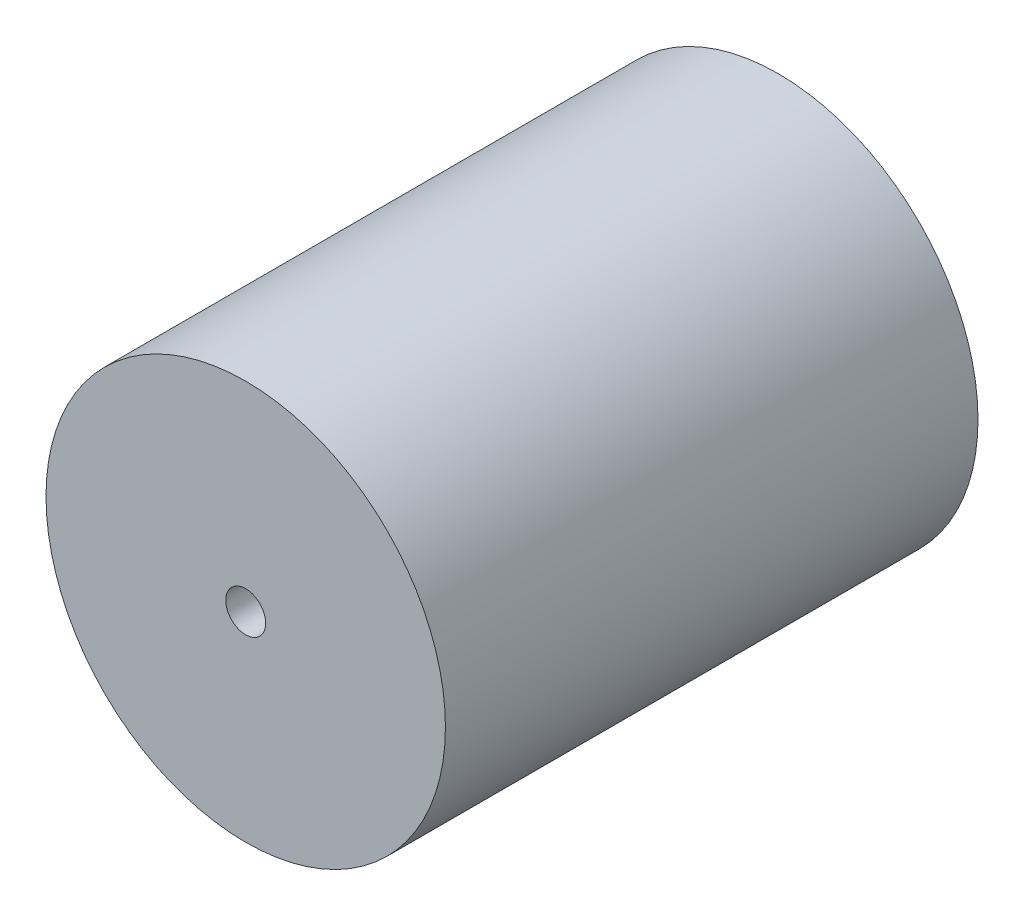
from build123d import *

# Parameters (mm, degrees)
CROQUIS1_R              = 15
CROQUIS1_R_2            = 1.5
SALIENTE_EXTRUIR1_DEPTH = 40


with BuildPart() as part:
    # Croquis1 → Saliente-Extruir1 (new body)
    with BuildSketch(Plane.XY):
        Circle(CROQUIS1_R)
        Circle(CROQUIS1_R_2, mode=Mode.SUBTRACT)
    extrude(amount=SALIENTE_EXTRUIR1_DEPTH)


solid = part.part
